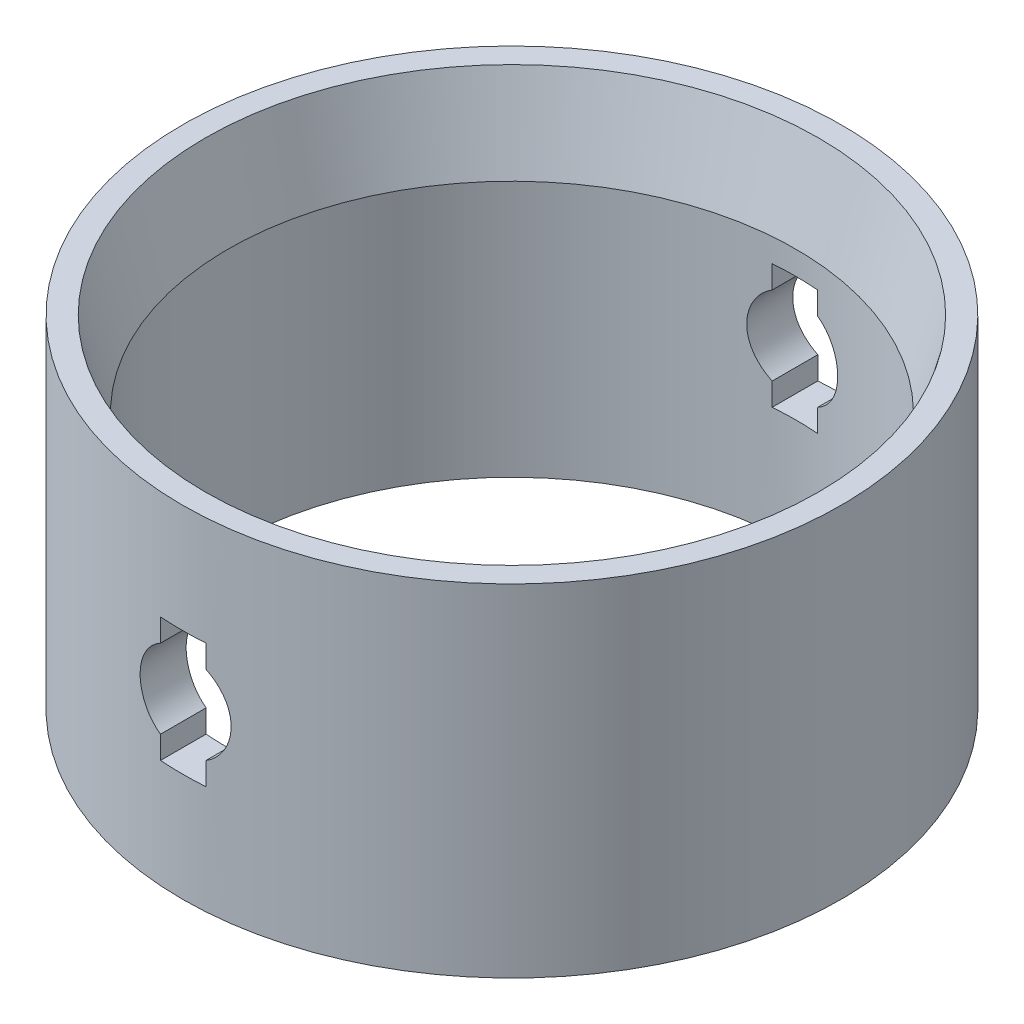
from build123d import *

# Parameters (mm, degrees)
SKETCH1_R               = 72.39
SKETCH1_R_2             = 62.39
BOSS_EXTRUDE1_DEPTH     = 75
CUT_EXTRUDE1_DEPTH      = 73.39
CUT_EXTRUDE1_DEPTH_BACK = 73.39
CHAMFER1_SIZE           = 5
CHAMFER1_SIZE2          = 18.660254038


with BuildPart() as part:
    # Sketch1 → Boss-Extrude1 (new body)
    with BuildSketch(Plane(origin=(0, 0, 0), x_dir=(1, 0, 0), z_dir=(0, 1, 0))):
        Circle(SKETCH1_R)
        Circle(SKETCH1_R_2, mode=Mode.SUBTRACT)
    extrude(amount=BOSS_EXTRUDE1_DEPTH)

    # Sketch2 → Cut-Extrude1 (cut, two sides)
    with BuildSketch(Plane.XY) as cut_extrude1_sk:
        with BuildLine():
            Line((5, 28.839745962), (5, 23.839745962))
            Line((5, 23.839745962), (-5, 23.839745962))
            Line((-5, 23.839745962), (-5, 28.839745962))
            ThreePointArc((-5, 28.839745962), (-10, 37.5), (-5, 46.160254038))
            Line((-5, 46.160254038), (-5, 51.160254038))
            Line((-5, 51.160254038), (5, 51.160254038))
            Line((5, 51.160254038), (5, 46.160254038))
            ThreePointArc((5, 46.160254038), (10, 37.5), (5, 28.839745962))
        make_face()
    extrude(amount=CUT_EXTRUDE1_DEPTH, mode=Mode.SUBTRACT)
    extrude(cut_extrude1_sk.sketch, amount=-CUT_EXTRUDE1_DEPTH_BACK, mode=Mode.SUBTRACT)

    # Chamfer1
    chamfer1_edges = [part.edges().sort_by_distance(p)[0] for p in [
        (-62.39, 75, 0),
    ]]
    chamfer1_side = [part.faces().sort_by_distance(p)[0] for p in [
        (-70.342501604, 75, 0),
    ]]
    chamfer(chamfer1_edges, length=CHAMFER1_SIZE, length2=CHAMFER1_SIZE2, reference=chamfer1_side[0])


solid = part.part
